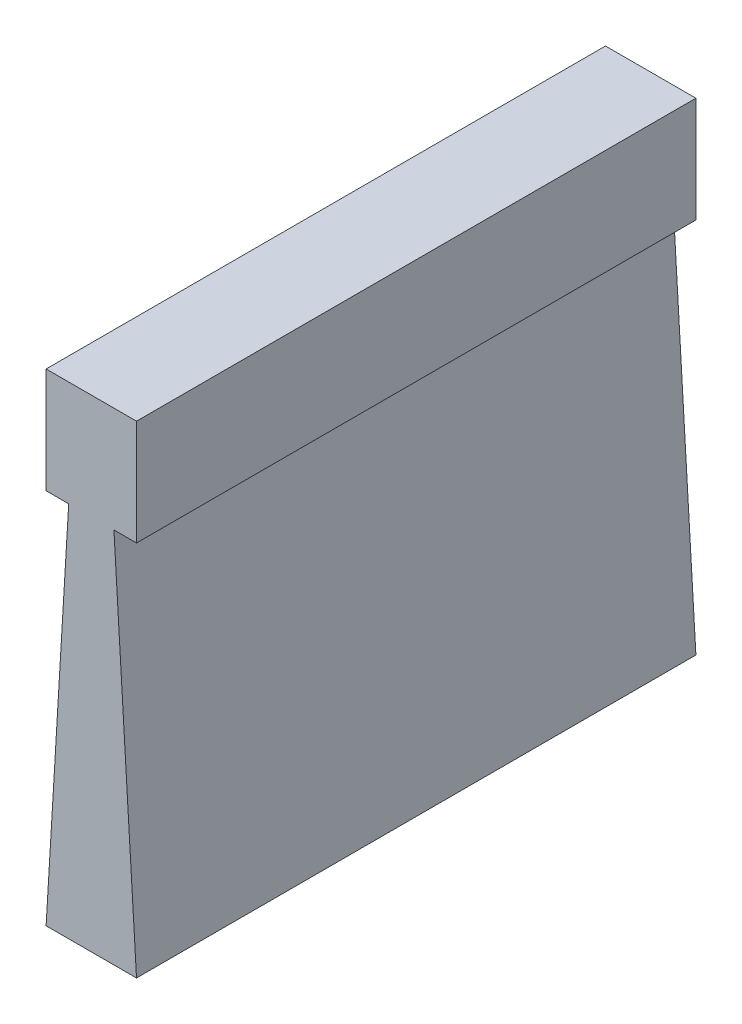
from build123d import *

# Parameters (mm, degrees)
BOSS_EXTRUDE1_DEPTH = 14.732


with BuildPart() as part:
    # Sketch1 → Boss-Extrude1 (new body, symmetric)
    with BuildSketch(Plane.XY):
        Polygon((-1.190625, 0), (-2.38125, 0), (-2.38125, 5.55625), (2.38125, 5.55625), (2.38125, 0), (1.190625, 0), (2.38125, -19.84375), (-2.38125, -19.84375), align=None)
    extrude(amount=BOSS_EXTRUDE1_DEPTH, both=True)


solid = part.part
